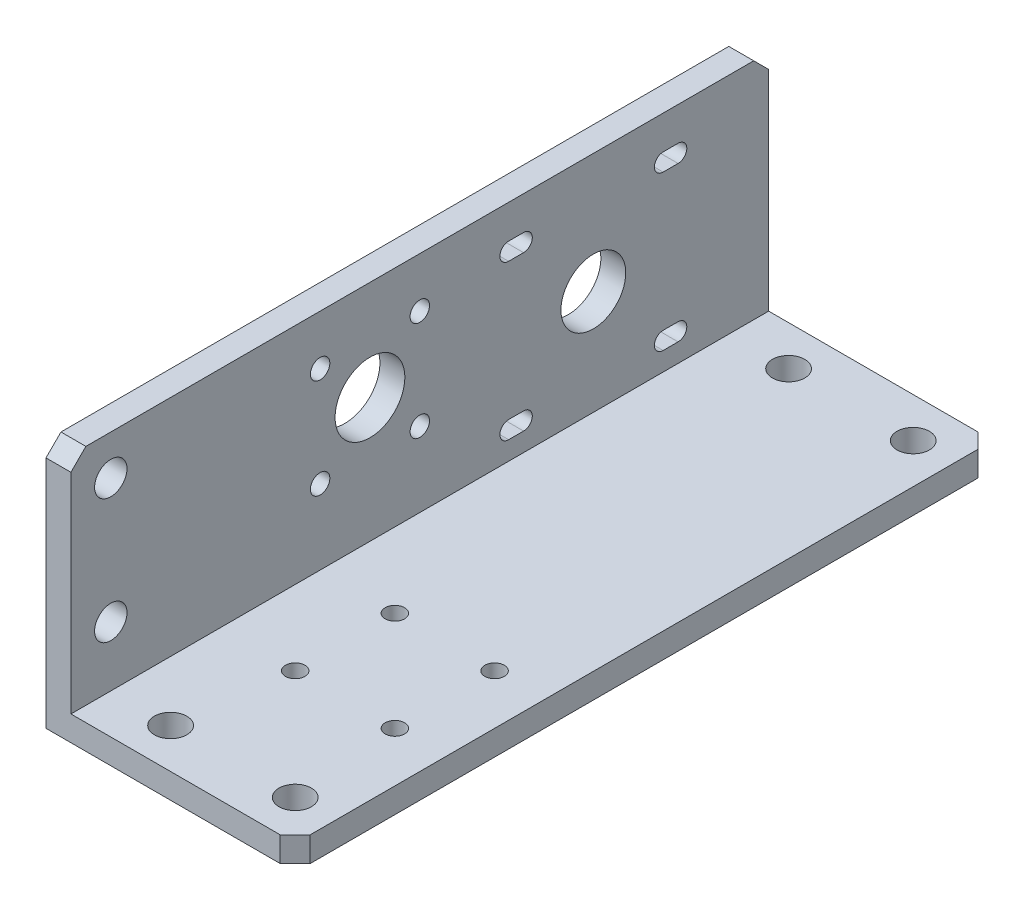
from build123d import *

# Parameters (mm, degrees)
ESTRUSIONE_ESTRUSIONE1_DEPTH = 140
FORO_6_5_6_5_1_D             = 6.5
FORO_6_5_6_5_2_D             = 6.5
FORO_6_5_6_5_2_DEPTH         = 5
FORO_6_5_6_5_2_TIP           = 1.952797012
TAGLIO_ESTRUSIONE3_REACH     = 52
SCHIZZO10_R                  = 7
TAGLIO_ESTRUSIONE6_REACH     = 52
SCHIZZO13_R                  = 6.5
SMUSSO1_SIZE                 = 3
M3_5_CLEARANCE_HOLE1_D       = 3.9
M3_5_CLEARANCE_HOLE2_D       = 3.9


with BuildPart() as part:
    # Schizzo1 → Estrusione-Estrusione1 (new body)
    with BuildSketch(Plane.XY):
        Polygon((0, 0), (0, 50), (5, 50), (5, 5), (50, 5), (50, 0), align=None)
    extrude(amount=ESTRUSIONE_ESTRUSIONE1_DEPTH)

    # Foro Ø6.5 (6.5)-1 (through all)
    with Locations(Plane(origin=(0, 0, 0), x_dir=(-1, 0, 0), z_dir=(0, -1, 0))):
        with Locations((-17, -132), (-42, -132)):
            foro_6_5_6_5_1 = Hole(FORO_6_5_6_5_1_D / 2)

    # Foro Ø6.5 (6.5)-2
    with Locations(Plane.ZY):
        with Locations((132, 42), (132, 17)):
            Hole(FORO_6_5_6_5_2_D / 2, depth=FORO_6_5_6_5_2_DEPTH)
            with Locations((0, 0, -(FORO_6_5_6_5_2_DEPTH + FORO_6_5_6_5_2_TIP / 2))):  # 118° drill point
                Cone(0, FORO_6_5_6_5_2_D / 2, FORO_6_5_6_5_2_TIP, mode=Mode.SUBTRACT)

    # Specchia1: Foro Ø6.5 (6.5)-1 across plane
    add(foro_6_5_6_5_1.mirror(Plane.XY.offset(70)), mode=Mode.SUBTRACT)

    # Schizzo10 → Taglio-Estrusione3 (cut, up to next)
    with BuildSketch(Plane.ZY, mode=Mode.PRIVATE) as taglio_estrusione3_sk1:
        with Locations((80, 30)):
            Circle(SCHIZZO10_R)
    taglio_estrusione3_tool1 = extrude(taglio_estrusione3_sk1.sketch, amount=-TAGLIO_ESTRUSIONE3_REACH, mode=Mode.PRIVATE) & part.part
    add(taglio_estrusione3_tool1.solids().sort_by_distance((0, 30, 80))[0], mode=Mode.SUBTRACT)

    # Schizzo13 → Taglio-Estrusione6 (cut, up to next)
    with BuildSketch(Plane.ZY, mode=Mode.PRIVATE) as taglio_estrusione6_sk1:
        with Locations((35.178130338, 26)):
            Circle(SCHIZZO13_R)
    taglio_estrusione6_tool1 = extrude(taglio_estrusione6_sk1.sketch, amount=-TAGLIO_ESTRUSIONE6_REACH, mode=Mode.PRIVATE) & part.part
    add(taglio_estrusione6_tool1.solids().sort_by_distance((0, 26, 35.17813))[0], mode=Mode.SUBTRACT)
    # Schizzo13 → Taglio-Estrusione6 (cut, up to next)
    with BuildSketch(Plane.ZY, mode=Mode.PRIVATE) as taglio_estrusione6_sk2:
        with BuildLine():
            Line((18.178130338, 43.25), (21.178130338, 43.25))
            ThreePointArc((21.178130338, 43.25), (22.928130338, 41.5), (21.178130338, 39.75))
            Line((21.178130338, 39.75), (18.178130338, 39.75))
            ThreePointArc((18.178130338, 39.75), (16.428130338, 41.5), (18.178130338, 43.25))
        make_face()
    taglio_estrusione6_tool2 = extrude(taglio_estrusione6_sk2.sketch, amount=-TAGLIO_ESTRUSIONE6_REACH, mode=Mode.PRIVATE) & part.part
    add(taglio_estrusione6_tool2.solids().sort_by_distance((0, 41.5, 19.67813))[0], mode=Mode.SUBTRACT)
    # Schizzo13 → Taglio-Estrusione6 (cut, up to next)
    with BuildSketch(Plane.ZY, mode=Mode.PRIVATE) as taglio_estrusione6_sk3:
        with BuildLine():
            Line((18.178130338, 8.75), (21.178130338, 8.75))
            ThreePointArc((21.178130338, 8.75), (22.928130338, 10.5), (21.178130338, 12.25))
            Line((21.178130338, 12.25), (18.178130338, 12.25))
            ThreePointArc((18.178130338, 12.25), (16.428130338, 10.5), (18.178130338, 8.75))
        make_face()
    taglio_estrusione6_tool3 = extrude(taglio_estrusione6_sk3.sketch, amount=-TAGLIO_ESTRUSIONE6_REACH, mode=Mode.PRIVATE) & part.part
    add(taglio_estrusione6_tool3.solids().sort_by_distance((0, 10.5, 19.67813))[0], mode=Mode.SUBTRACT)
    # Schizzo13 → Taglio-Estrusione6 (cut, up to next)
    with BuildSketch(Plane.ZY, mode=Mode.PRIVATE) as taglio_estrusione6_sk4:
        with BuildLine():
            Line((52.178130338, 43.25), (49.178130338, 43.25))
            ThreePointArc((49.178130338, 43.25), (47.428130338, 41.5), (49.178130338, 39.75))
            Line((49.178130338, 39.75), (52.178130338, 39.75))
            ThreePointArc((52.178130338, 39.75), (53.928130338, 41.5), (52.178130338, 43.25))
        make_face()
    taglio_estrusione6_tool4 = extrude(taglio_estrusione6_sk4.sketch, amount=-TAGLIO_ESTRUSIONE6_REACH, mode=Mode.PRIVATE) & part.part
    add(taglio_estrusione6_tool4.solids().sort_by_distance((0, 41.5, 50.67813))[0], mode=Mode.SUBTRACT)
    # Schizzo13 → Taglio-Estrusione6 (cut, up to next)
    with BuildSketch(Plane.ZY, mode=Mode.PRIVATE) as taglio_estrusione6_sk5:
        with BuildLine():
            Line((52.178130338, 8.75), (49.178130338, 8.75))
            ThreePointArc((49.178130338, 8.75), (47.428130338, 10.5), (49.178130338, 12.25))
            Line((49.178130338, 12.25), (52.178130338, 12.25))
            ThreePointArc((52.178130338, 12.25), (53.928130338, 10.5), (52.178130338, 8.75))
        make_face()
    taglio_estrusione6_tool5 = extrude(taglio_estrusione6_sk5.sketch, amount=-TAGLIO_ESTRUSIONE6_REACH, mode=Mode.PRIVATE) & part.part
    add(taglio_estrusione6_tool5.solids().sort_by_distance((0, 10.5, 50.67813))[0], mode=Mode.SUBTRACT)

    # Smusso1
    smusso1_edges = [part.edges().sort_by_distance(p)[0] for p in [
        (2.5, 50, 140),
        (2.5, 50, 0),
        (50, 2.5, 140),
        (50, 2.5, 0),
    ]]
    chamfer(smusso1_edges, length=SMUSSO1_SIZE)

    # M3.5 Clearance Hole1 (through all)
    with Locations(Plane(origin=(0, 40, 70), x_dir=(0, 0, -1), z_dir=(-1, 0, 0))):
        with Locations((0, 0), (-20, 0), (-20, 20), (0, 20)):
            Hole(M3_5_CLEARANCE_HOLE1_D / 2)

    # M3.5 Clearance Hole2 (through all)
    with Locations(Plane(origin=(20, 0, 110), x_dir=(-1, 0, 0), z_dir=(0, -1, 0))):
        with Locations((0, 0), (-20, 0), (-20, 20), (0, 20)):
            Hole(M3_5_CLEARANCE_HOLE2_D / 2)


solid = part.part
